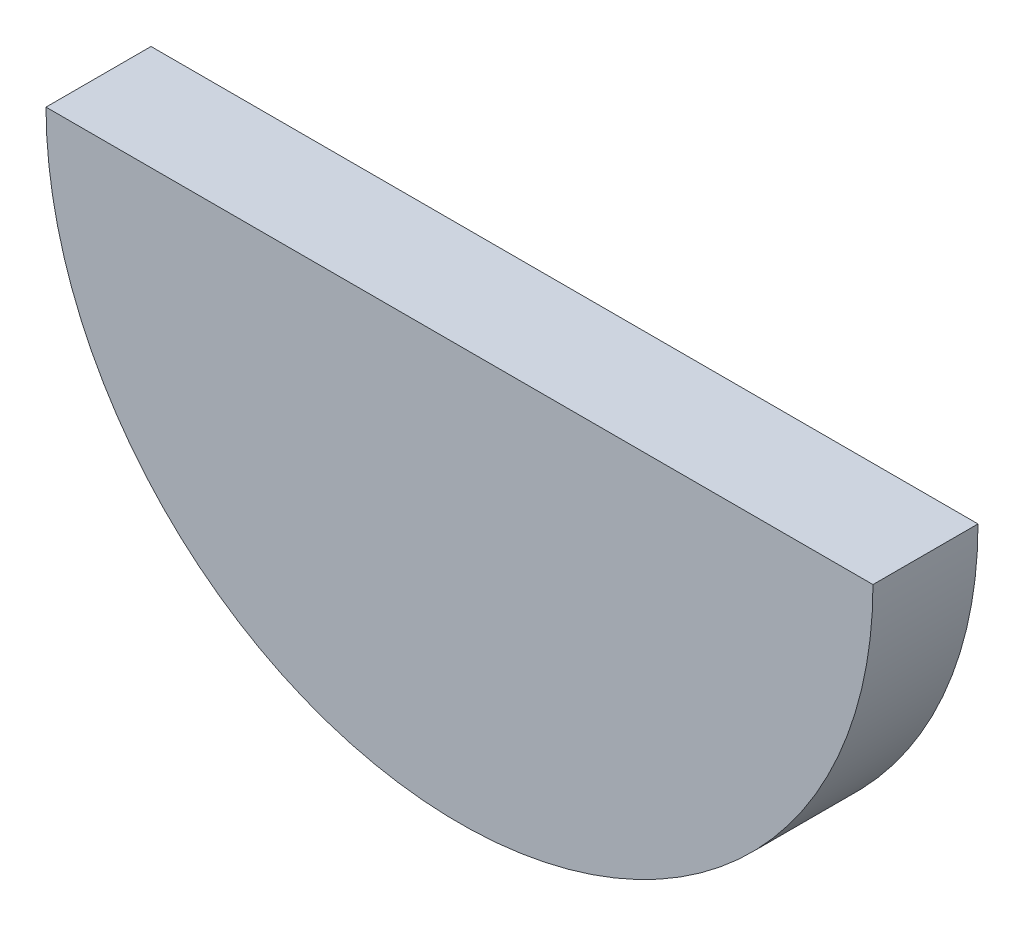
from build123d import *

# Parameters (mm, degrees)
BOSS_EXTRUDE1_DEPTH = 101.6


with BuildPart() as part:
    # Sketch1 → Boss-Extrude1 (new body)
    with BuildSketch(Plane.XY):
        with BuildLine():
            Line((-400, 0), (400, 0))
            ThreePointArc((400, 0), (0, -400), (-400, 0))
        make_face()
    extrude(amount=BOSS_EXTRUDE1_DEPTH)


solid = part.part
